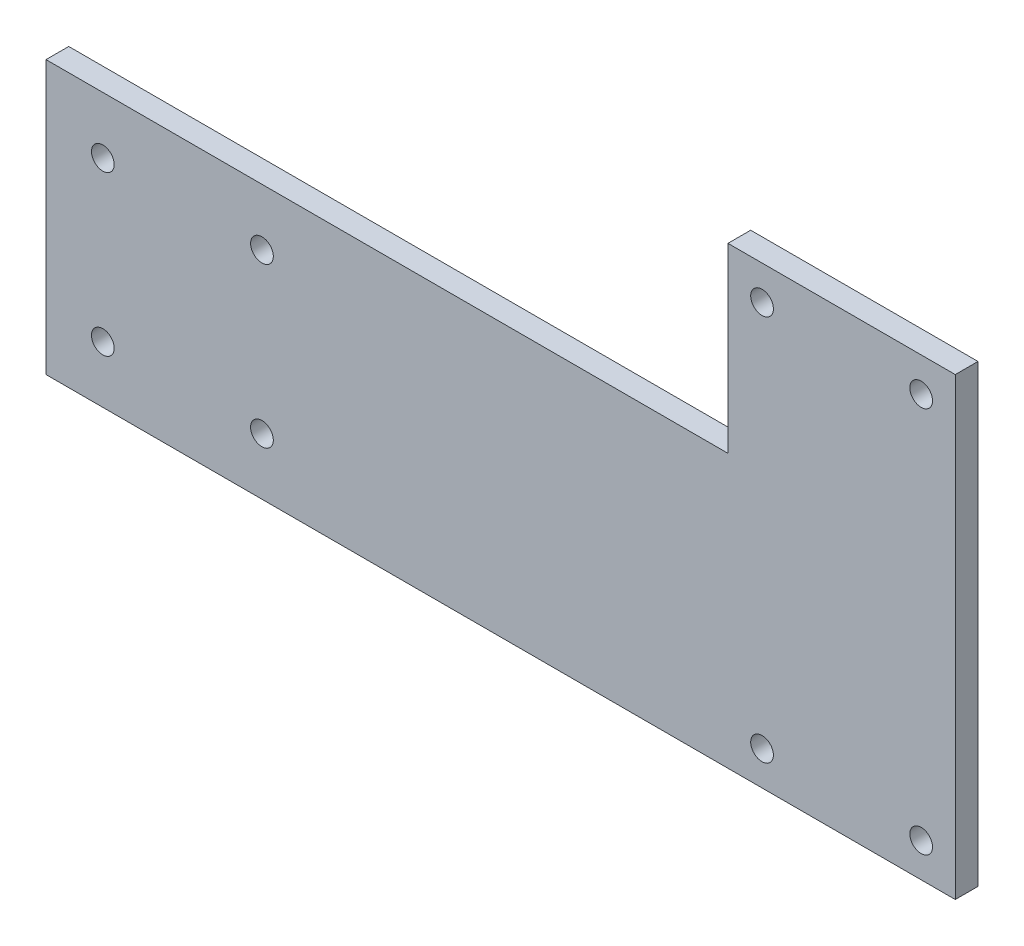
from build123d import *

# Parameters (mm, degrees)
SKETCH1_W           = 200
SKETCH1_H           = 100
SKETCH1_R           = 2.5
BOSS_EXTRUDE1_DEPTH = 5
SKETCH2_R           = 2.5
CUT_EXTRUDE1_DEPTH  = 5
SKETCH4_W           = 150
SKETCH4_H           = 40
CUT_EXTRUDE3_DEPTH  = 30


with BuildPart() as part:
    # Sketch1 → Boss-Extrude1 (new body)
    with BuildSketch(Plane.XY):
        Rectangle(SKETCH1_W, SKETCH1_H)
        with Locations((-92.5, 42.5)):
            Circle(SKETCH1_R, mode=Mode.SUBTRACT)
        with Locations((-57.5, 42.5)):
            Circle(SKETCH1_R, mode=Mode.SUBTRACT)
        with Locations((57.5, -42.5)):
            Circle(SKETCH1_R, mode=Mode.SUBTRACT)
        with Locations((92.5, -42.5)):
            Circle(SKETCH1_R, mode=Mode.SUBTRACT)
        with Locations((57.5, 42.5)):
            Circle(SKETCH1_R, mode=Mode.SUBTRACT)
        with Locations((92.5, 42.5)):
            Circle(SKETCH1_R, mode=Mode.SUBTRACT)
        with Locations((-87.5, -37.5)):
            Circle(SKETCH1_R, mode=Mode.SUBTRACT)
        with Locations((-52.5, -37.5)):
            Circle(SKETCH1_R, mode=Mode.SUBTRACT)
    extrude(amount=BOSS_EXTRUDE1_DEPTH)

    # Sketch2 → Cut-Extrude1 (cut)
    with BuildSketch(Plane.XY.offset(5)):
        with Locations((-87.5, -2.5)):
            Circle(SKETCH2_R)
        with Locations((-52.5, -2.5)):
            Circle(SKETCH2_R)
        with Locations((-87.5, -37.5)):
            Circle(SKETCH2_R)
        with Locations((-52.5, -37.5)):
            Circle(SKETCH2_R)
    extrude(amount=-CUT_EXTRUDE1_DEPTH, mode=Mode.SUBTRACT)

    # Sketch4 → Cut-Extrude3 (cut)
    with BuildSketch(Plane.XY.offset(5)):
        with Locations((-25, 30)):
            Rectangle(SKETCH4_W, SKETCH4_H)
    extrude(amount=-CUT_EXTRUDE3_DEPTH, mode=Mode.SUBTRACT)


solid = part.part
